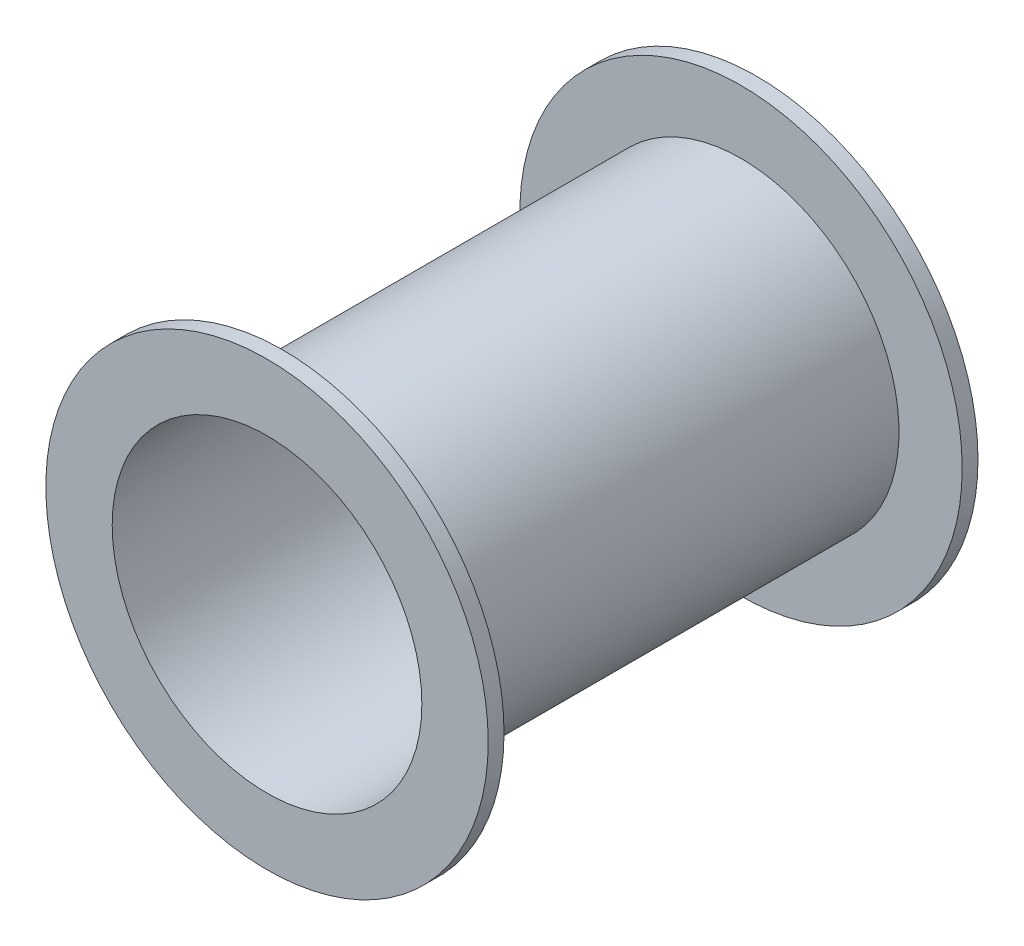
from build123d import *

# Parameters (mm, degrees)
SKETCH2_R           = 100
SKETCH2_R_2         = 98
EXTRUDE_THIN1_DEPTH = 310
SKETCH3_R           = 140
SKETCH3_R_2         = 100
BOSS_EXTRUDE1_DEPTH = 10


with BuildPart() as part:
    # Sketch2 → Extrude-Thin1 (new body)
    with BuildSketch(Plane.XY):
        Circle(SKETCH2_R)
        Circle(SKETCH2_R_2, mode=Mode.SUBTRACT)
    extrude(amount=EXTRUDE_THIN1_DEPTH)

    # Sketch3 → Boss-Extrude1 (add)
    with BuildSketch(Plane.XY.offset(310)):
        Circle(SKETCH3_R)
        Circle(SKETCH3_R_2, mode=Mode.SUBTRACT)
    boss_extrude1 = extrude(amount=-BOSS_EXTRUDE1_DEPTH)

    # Mirror1: Boss-Extrude1 across plane
    add(boss_extrude1.mirror(Plane.XY.offset(155)))


solid = part.part
